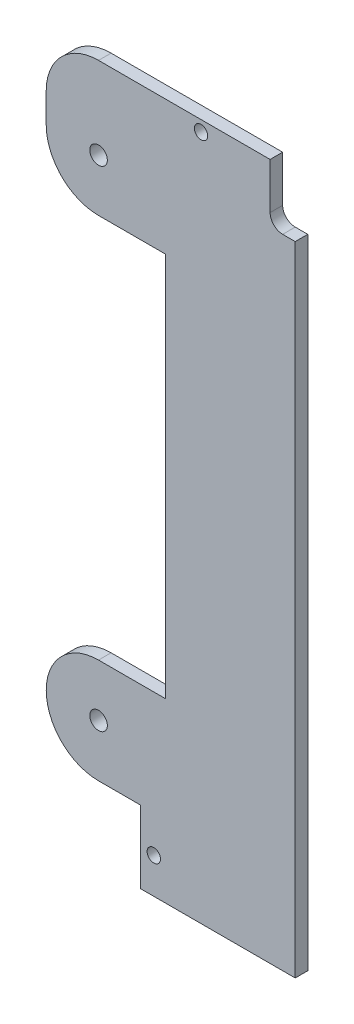
from build123d import *

# Parameters (mm, degrees)
SKETCH1_R           = 2.1
SKETCH1_R_2         = 1.6
BOSS_EXTRUDE1_DEPTH = 3


with BuildPart() as part:
    # Sketch1 → Boss-Extrude1 (new body)
    with BuildSketch(Plane.XY):
        with BuildLine():
            Line((41, 136.6), (41, 125.6))
            ThreePointArc((41, 125.6), (41.878679656, 123.478679656), (44, 122.6))
            Line((44, 122.6), (47, 122.6))
            Line((47, 122.6), (47, -29.8))
            Line((47, -29.8), (10, -29.8))
            Line((10, -29.8), (10, -12.5))
            Line((10, -12.5), (0, -12.5))
            ThreePointArc((0, -12.5), (-12.5, 0), (0, 12.5))
            Line((0, 12.5), (16, 12.5))
            Line((16, 12.5), (16, 104.5))
            Line((16, 104.5), (0, 104.5))
            ThreePointArc((0, 104.5), (-8.838834765, 108.161165235), (-12.5, 117))
            Line((-12.5, 117), (-12.5, 124.1))
            ThreePointArc((-12.5, 124.1), (-8.838834765, 132.938834765), (0, 136.6))
            Line((0, 136.6), (41, 136.6))
        make_face()
        Circle(SKETCH1_R, mode=Mode.SUBTRACT)
        with Locations((0, 117)):
            Circle(SKETCH1_R, mode=Mode.SUBTRACT)
        with Locations((13.2, -21.3)):
            Circle(SKETCH1_R_2, mode=Mode.SUBTRACT)
        with Locations((24.5, 134)):
            Circle(SKETCH1_R_2, mode=Mode.SUBTRACT)
    extrude(amount=BOSS_EXTRUDE1_DEPTH)


solid = part.part
